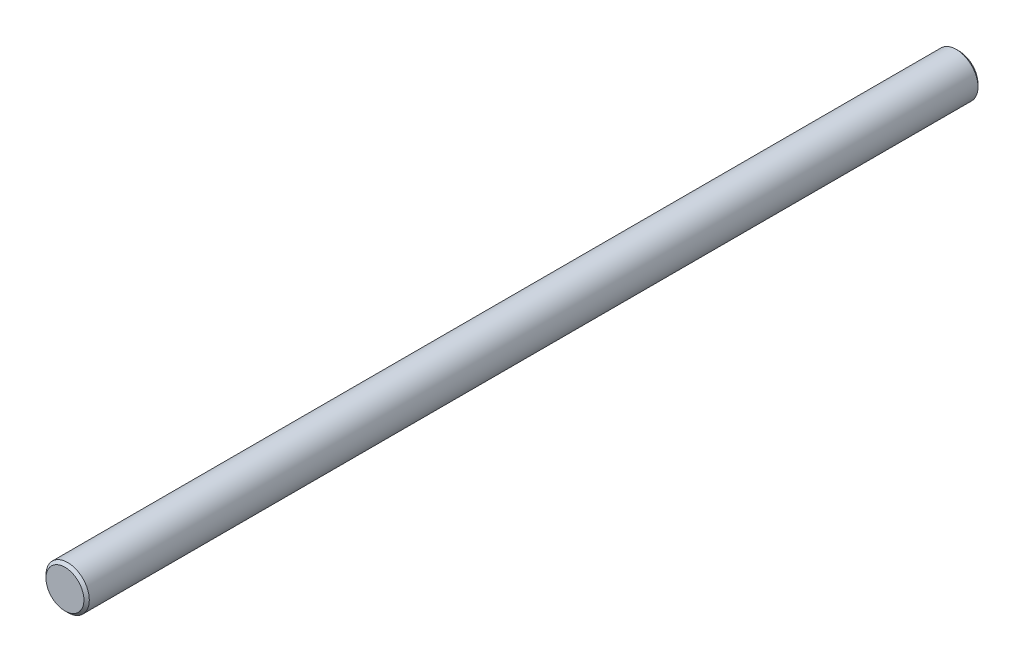
from build123d import *

# Parameters (mm, degrees)
SKETCH1_R           = 4
BOSS_EXTRUDE1_DEPTH = 165
CHAMFER1_SIZE       = 0.5


with BuildPart() as part:
    # Sketch1 → Boss-Extrude1 (new body)
    with BuildSketch(Plane.XY):
        Circle(SKETCH1_R)
    extrude(amount=BOSS_EXTRUDE1_DEPTH)

    # Chamfer1
    chamfer1_edges = [part.edges().sort_by_distance(p)[0] for p in [
        (-4, 0, 0),
        (-4, 0, 165),
    ]]
    chamfer(chamfer1_edges, length=CHAMFER1_SIZE)


solid = part.part
